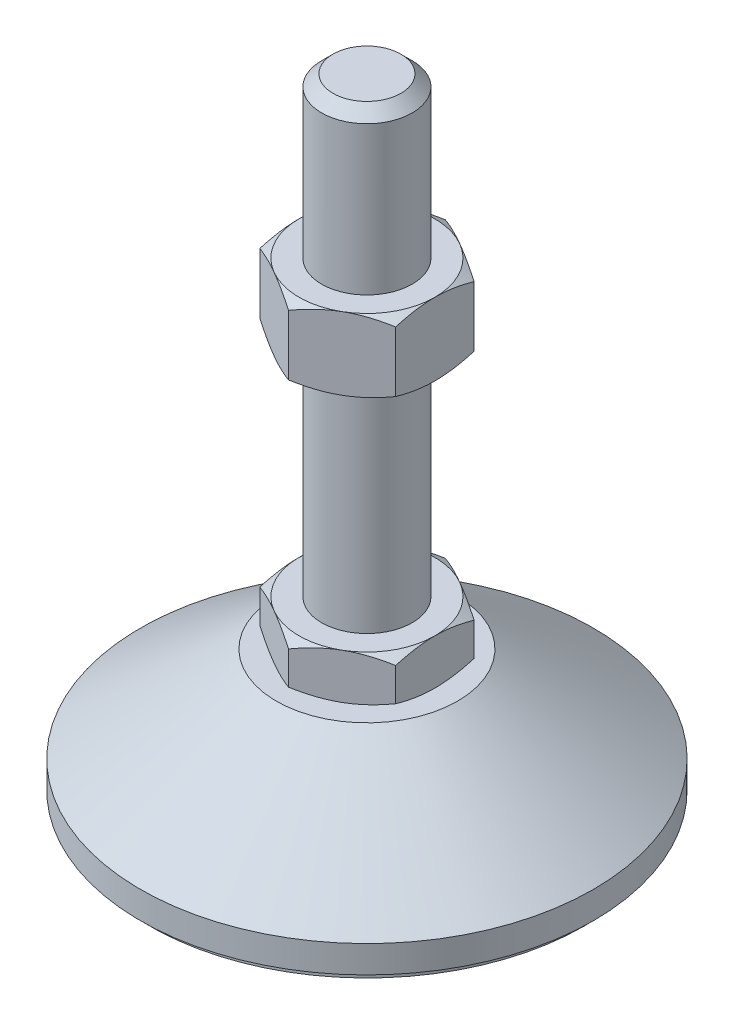
from build123d import *

# Parameters (mm, degrees)
EXTRUDE_1_DEPTH = 10
EXTRUDE_2_DEPTH = 16


with BuildPart() as part:
    # Эскиз1 → Повернуть1 (revolve)
    with BuildSketch(Plane.XY, mode=Mode.PRIVATE) as revolve_1_sk:
        Polygon((0, 0), (-48, 0), (-48, 2), (-50, 2), (-50, 8), (-20, 29), (-10, 29), (-10, 39), (-10, 136.5), (-7.5, 139), (0, 139), align=None)
    revolve(revolve_1_sk.sketch.rotate(Axis((0, 0, 0), (0, 1, 0)), 180), axis=Axis((0, 0, 0), (0, 1, 0)))  # turned: the seam where the file's is

    # Эскиз2 → Бобышка-Вытянуть1 (add)
    with BuildSketch(Plane(origin=(0, 29, 0), x_dir=(1, 0, 0), z_dir=(0, 1, 0))):
        Polygon((0, 17.320508076), (-15, 8.660254038), (-15, -8.660254038), (0, -17.320508076), (15, -8.660254038), (15, 8.660254038), align=None)
    extrude(amount=EXTRUDE_1_DEPTH)

    # Эскиз3 → Бобышка-Вытянуть2 (add)
    with BuildSketch(Plane(origin=(0, 87.75, 0), x_dir=(1, 0, 0), z_dir=(0, 1, 0))):
        Polygon((15, 8.660254038), (0, 17.320508076), (-15, 8.660254038), (-15, -8.660254038), (0, -17.320508076), (15, -8.660254038), align=None)
    extrude(amount=EXTRUDE_2_DEPTH)

    # Эскиз4 → Вырез-Повернуть2 (revolve, cut)
    with BuildSketch(Plane.XY, mode=Mode.PRIVATE) as cut_revolve_2_sk:
        Polygon((-28.856406461, 103.75), (-15, 103.75), (-28.856406461, 95.75), align=None)
        Polygon((-28.856406461, 87.75), (-28.856406461, 95.75), (-15, 87.75), align=None)
        Polygon((-23.660254038, 39), (-23.660254038, 34), (-15, 39), align=None)
        Polygon((-23.660254038, 34), (-23.660254038, 29), (-15, 29), align=None)
    revolve(cut_revolve_2_sk.sketch.rotate(Axis((0, 139, 0), (0, -1, 0)), 180), axis=Axis((0, 139, 0), (0, -1, 0)), mode=Mode.SUBTRACT)  # turned: the seam where the file's is


solid = part.part
